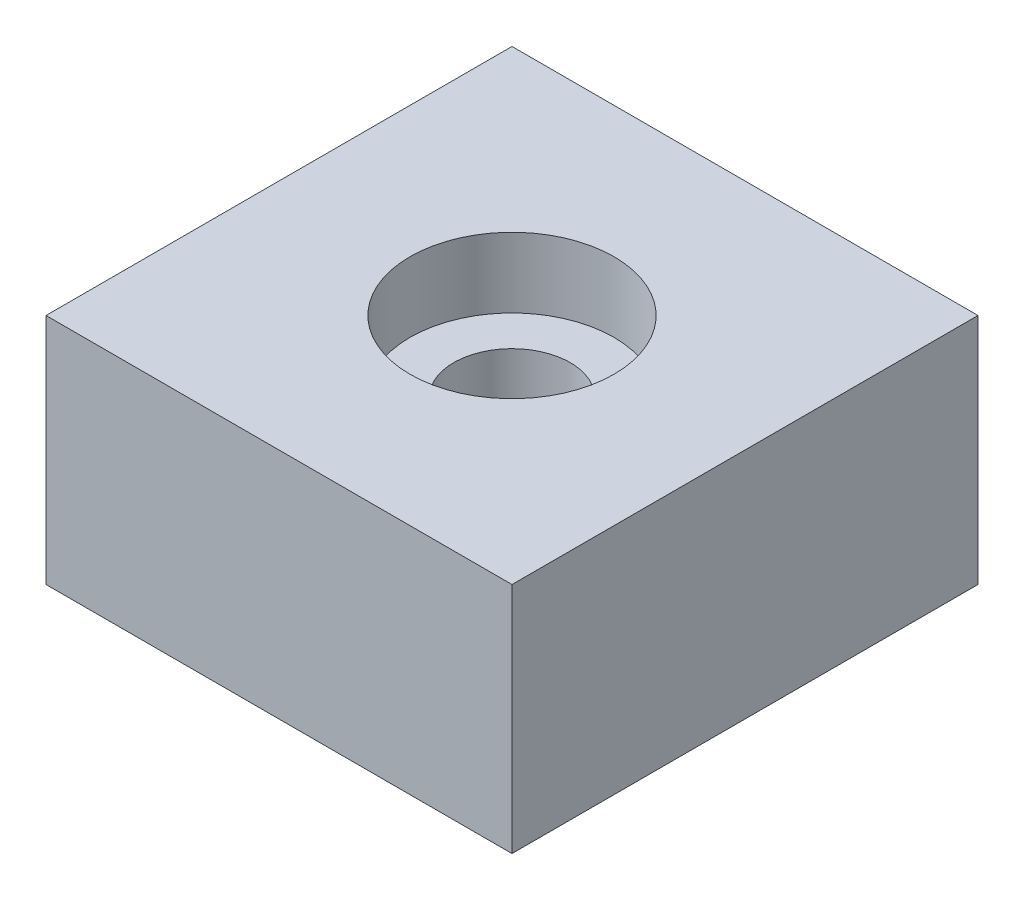
from build123d import *

# Parameters (mm, degrees)
SKETCH1_W           = 50.8
SKETCH1_H           = 50.8
BOSS_EXTRUDE1_DEPTH = 25.4
SKETCH6_R           = 6.35
CUT_EXTRUDE1_DEPTH  = 25.4
SKETCH7_R           = 11.1125
CUT_EXTRUDE2_DEPTH  = 7.62


with BuildPart() as part:
    # Sketch1 → Boss-Extrude1 (new body)
    with BuildSketch(Plane(origin=(0, 0, 0), x_dir=(1, 0, 0), z_dir=(0, 1, 0))):
        with Locations((25.4, 25.4)):
            Rectangle(SKETCH1_W, SKETCH1_H)
    extrude(amount=BOSS_EXTRUDE1_DEPTH)

    # Sketch6 → Cut-Extrude1 (cut)
    with BuildSketch(Plane(origin=(0, 25.4, 0), x_dir=(1, 0, 0), z_dir=(0, 1, 0))):
        with Locations((25.4, 25.4)):
            Circle(SKETCH6_R)
    extrude(amount=-CUT_EXTRUDE1_DEPTH, mode=Mode.SUBTRACT)

    # Sketch7 → Cut-Extrude2 (cut)
    with BuildSketch(Plane(origin=(0, 25.4, 0), x_dir=(1, 0, 0), z_dir=(0, 1, 0))):
        with Locations((25.4, 25.4)):
            Circle(SKETCH7_R)
    extrude(amount=-CUT_EXTRUDE2_DEPTH, mode=Mode.SUBTRACT)


solid = part.part
